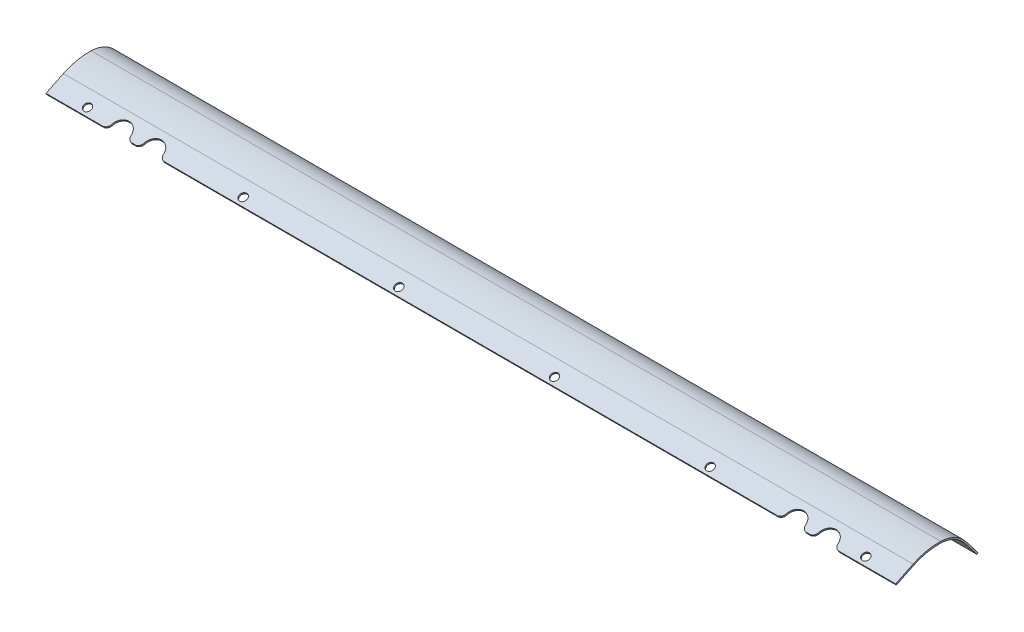
from build123d import *

# Parameters (mm, degrees)
BOSS_EXTRUDE1_DEPTH = 415.925
SKETCH2_R           = 1.905
SKETCH2_R_2         = 4.7625
CUT_EXTRUDE1_DEPTH  = 33.12004037
SKETCH3_R           = 1.905
SKETCH3_R_2         = 4.7625
CUT_EXTRUDE2_DEPTH  = 25.148192008
FILLET1_R           = 2.54


with BuildPart() as part:
    # Sketch1 → Boss-Extrude1 (new body)
    with BuildSketch(Plane(origin=(0, 0, 0), x_dir=(0, 0, -1), z_dir=(1, 0, 0))):
        with BuildLine():
            Line((0, 0), (8.544034092, 4.140587208))
            ThreePointArc((8.544034092, 4.140587208), (15.154293004, 6.402142447), (22.11465741, 7.005037384))
            ThreePointArc((22.11465741, 7.005037384), (28.990873234, 5.219587953), (34.462291588, 0.688169311))
            Line((34.462291588, 0.688169311), (40.304254396, -6.834934806))
            Line((40.304254396, -6.834934806), (39.702406066, -7.302291831))
            Line((39.702406066, -7.302291831), (33.860443258, 0.220812286))
            ThreePointArc((33.860443258, 0.220812286), (28.578549484, 4.578836813), (21.941212592, 6.263039476))
            ThreePointArc((21.941212592, 6.263039476), (15.239798668, 5.645126355), (8.876346175, 3.454866653))
            Line((8.876346175, 3.454866653), (0.332312082, -0.685720555))
            Line((0.332312082, -0.685720555), (0, 0))
        make_face()
    extrude(amount=BOSS_EXTRUDE1_DEPTH)

    # Sketch2 → Cut-Extrude1 (cut, through all)
    with BuildSketch(Plane(origin=(0, 16.953241071, -21.8318743), x_dir=(-1, 0, 0), z_dir=(0, 0.613329429, -0.789827204))):
        with Locations((-398.4625, -26.892718875)):
            Circle(SKETCH2_R)
        with Locations((-322.2625, -26.892718875)):
            Circle(SKETCH2_R)
        with Locations((-246.0625, -26.892718875)):
            Circle(SKETCH2_R)
        with Locations((-169.8625, -26.892718875)):
            Circle(SKETCH2_R)
        with Locations((-93.6625, -26.892718875)):
            Circle(SKETCH2_R)
        with Locations((-17.4625, -26.892718875)):
            Circle(SKETCH2_R)
        with Locations((-381, -28.480218875)):
            Circle(SKETCH2_R_2)
        with Locations((-365.125, -28.480218875)):
            Circle(SKETCH2_R_2)
        with Locations((-50.8, -28.480218875)):
            Circle(SKETCH2_R_2)
        with Locations((-34.925, -28.480218875)):
            Circle(SKETCH2_R_2)
    extrude(amount=-CUT_EXTRUDE1_DEPTH, mode=Mode.SUBTRACT)

    # Sketch3 → Cut-Extrude2 (cut, through all)
    with BuildSketch(Plane(origin=(0, 0, 0), x_dir=(1, 0, 0), z_dir=(0, 0.899895742, 0.436105095))):
        with Locations((398.4625, 3.175)):
            Circle(SKETCH3_R)
        with Locations((322.2625, 3.175)):
            Circle(SKETCH3_R)
        with Locations((246.0625, 3.175)):
            Circle(SKETCH3_R)
        with Locations((169.8625, 3.175)):
            Circle(SKETCH3_R)
        with Locations((93.6625, 3.175)):
            Circle(SKETCH3_R)
        with Locations((17.4625, 3.175)):
            Circle(SKETCH3_R)
        with Locations((365.125, 1.5875)):
            Circle(SKETCH3_R_2)
        with Locations((381, 1.5875)):
            Circle(SKETCH3_R_2)
        with Locations((34.925, 1.5875)):
            Circle(SKETCH3_R_2)
        with Locations((50.8, 1.5875)):
            Circle(SKETCH3_R_2)
    extrude(amount=-CUT_EXTRUDE2_DEPTH, mode=Mode.SUBTRACT)

    # Fillet1
    fillet1_edges = [part.edges().sort_by_distance(p)[0] for p in [
        (360.634871939, -0.342860278, -0.166156041),
        (369.615128061, -0.342860278, -0.166156041),
        (376.509871939, -0.342860278, -0.166156041),
        (385.490128061, -0.342860278, -0.166156041),
        (30.434871939, -0.342860278, -0.166156041),
        (39.415128061, -0.342860278, -0.166156041),
        (46.309871939, -0.342860278, -0.166156041),
        (55.290128061, -0.342860278, -0.166156041),
        (385.471958745, -7.068613318, -40.003330231),
        (376.528041255, -7.068613318, -40.003330231),
        (369.596958745, -7.068613318, -40.003330231),
        (360.653041255, -7.068613318, -40.003330231),
        (55.271958745, -7.068613318, -40.003330231),
        (46.328041255, -7.068613318, -40.003330231),
        (39.396958745, -7.068613318, -40.003330231),
        (30.453041255, -7.068613318, -40.003330231),
    ]]
    fillet(fillet1_edges, radius=FILLET1_R)


solid = part.part
